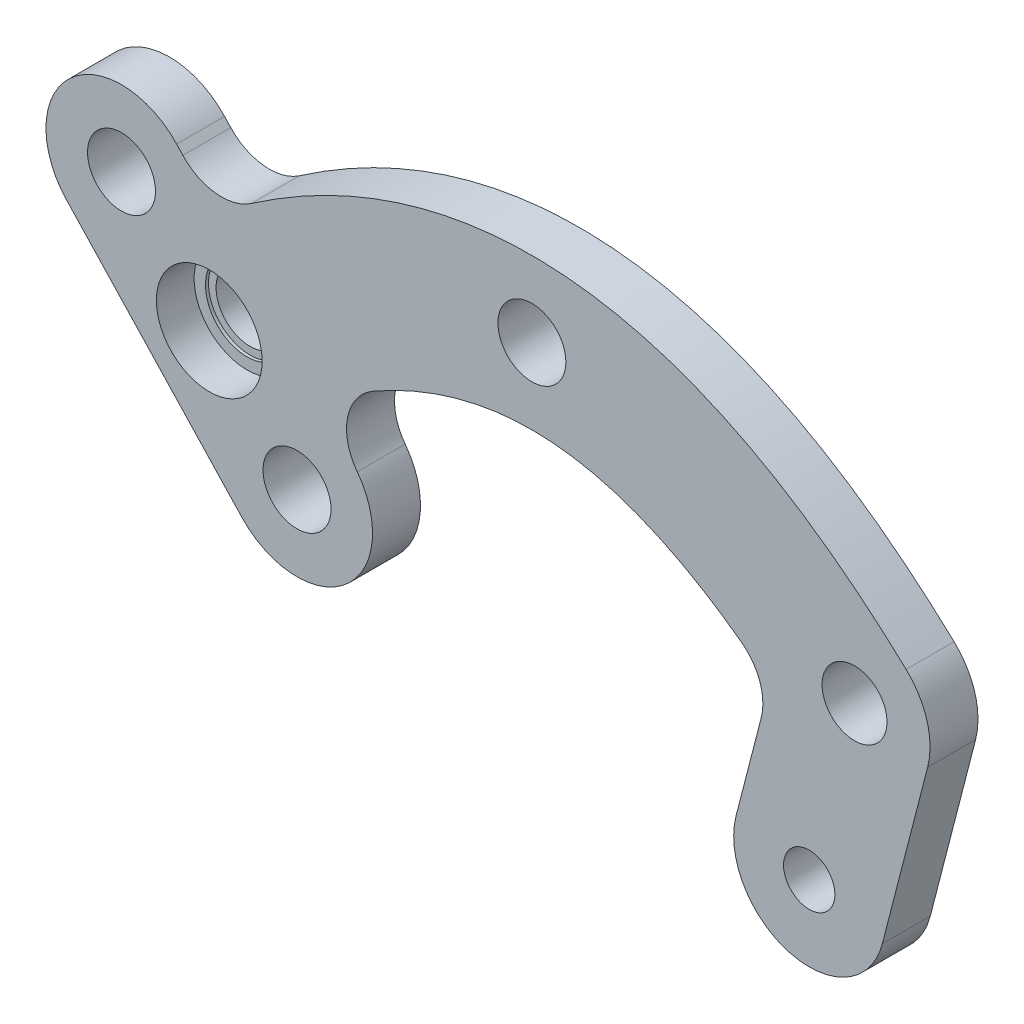
from build123d import *

# Parameters (mm, degrees)
BOSS_EXTRUDE1_DEPTH  = 1.5875
M4_CLEARANCE_HOLE1_D = 4.5
BOSS_EXTRUDE2_DEPTH  = 3.175
M3_CLEARANCE_HOLE1_D = 3.4
FILLET1_R            = 3.5
SKETCH8_R            = 2.15
CUT_EXTRUDE1_DEPTH   = 4.1750001
SKETCH9_R            = 2.75
SKETCH9_R_2          = 2.15
BOSS_EXTRUDE3_DEPTH  = 0.75
SKETCH11_R           = 3.5
CUT_EXTRUDE2_DEPTH   = 2.5
SKETCH12_R           = 2.75
CUT_EXTRUDE3_DEPTH   = 0.2
SKETCH13_R           = 3
SKETCH13_R_2         = 2.25
BOSS_EXTRUDE5_DEPTH  = 1.5


with BuildPart() as part:
    # Sketch2 → Boss-Extrude1 (new body, symmetric)
    with BuildSketch(Plane.XY):
        with BuildLine():
            add(Edge.make_bspline(
                [(-24.777431429, -6.350183234), (-24.299810251, -5.902972393), (-23.32289496, -5.01651393), (-22.058866471, -3.944003435), (-21.276036232, -3.316259916), (-20.98344634, -3.086723573)],
                knots=[0, 0, 0, 0, 0.03125, 0.0625, 0.081068463, 0.081068463, 0.081068463, 0.081068463], degree=3))
            Line((-24.777431429, -6.350183234), (-21.36, -10))
            add(Edge.make_bspline(
                [(-21.36, -10), (-20.09052587, -8.81135381), (-18.821051739, -7.728673603), (-17.551577609, -6.751959378)],
                knots=[0, 0, 0, 0, 0.089148464, 0.089148464, 0.089148464, 0.089148464], degree=3))
            Line((-17.551577609, -6.751959378), (-20.98344634, -3.086723573))
        make_face()
        with BuildLine():
            Line((-21.36, -10), (-24.777431429, -6.350183234))
            ThreePointArc((-24.777431429, -6.350183234), (-26.357299125, -9.8356788), (-25.009816701, -13.417431499))
            ThreePointArc((-25.009816701, -13.417431499), (-21.5243212, -14.997299125), (-17.942568571, -13.649816766))
            Line((-17.942568571, -13.649816766), (-21.36, -10))
        make_face()
        with BuildLine():
            ThreePointArc((-25.009816701, -13.417431499), (-26.357299125, -9.8356788), (-24.777431429, -6.350183234))
            add(Edge.make_bspline(
                [(-24.777431429, -6.350183234), (-24.299810251, -5.902972393), (-23.32289496, -5.01651393), (-22.058866471, -3.944003435), (-21.276036232, -3.316259916), (-20.98344634, -3.086723573)],
                knots=[0, 0, 0, 0, 0.03125, 0.0625, 0.081068463, 0.081068463, 0.081068463, 0.081068463], degree=3))
            Line((-20.98344634, -3.086723573), (-21.127614663, -2.932751805))
            Line((-21.127614663, -2.932751805), (-23.519816663, -0.377880068))
            ThreePointArc((-23.519816663, -0.377880068), (-30.587064859, -0.145494731), (-30.819450196, -7.212742926))
            Line((-30.819450196, -7.212742926), (-28.427248195, -9.767614663))
            Line((-28.427248195, -9.767614663), (-25.009816701, -13.417431499))
        make_face()
        with BuildLine():
            add(Edge.make_bspline(
                [(-21.36, -10), (-20.09052587, -8.81135381), (-18.821051739, -7.728673603), (-17.551577609, -6.751959378)],
                knots=[0, 0, 0, 0, 0.089148464, 0.089148464, 0.089148464, 0.089148464], degree=3))
            Line((-21.36, -10), (-17.942568571, -13.649816766))
            add(Edge.make_bspline(
                [(-17.942568571, -13.649816766), (-17.543072686, -13.275756949), (-16.7212792, -12.530114496), (-15.44829951, -11.450473224), (-14.582019434, -10.770813046), (-14.116024052, -10.421130577)],
                knots=[0, 0, 0, 0, 0.03125, 0.0625, 0.099339971, 0.099339971, 0.099339971, 0.099339971], degree=3))
            Line((-14.116024052, -10.421130577), (-14.292751805, -10.232385337))
            Line((-14.292751805, -10.232385337), (-17.551577609, -6.751959378))
        make_face()
        with BuildLine():
            ThreePointArc((-17.942568571, -13.649816766), (-21.5243212, -14.997299125), (-25.009816701, -13.417431499))
            Line((-25.009816701, -13.417431499), (-21.592385337, -17.067248195))
            Line((-21.592385337, -17.067248195), (-19.200183337, -19.622119932))
            ThreePointArc((-19.200183337, -19.622119932), (-12.132935141, -19.854505269), (-11.900549804, -12.787257074))
            Line((-11.900549804, -12.787257074), (-14.116024052, -10.421130577))
            add(Edge.make_bspline(
                [(-17.942568571, -13.649816766), (-17.543072686, -13.275756949), (-16.7212792, -12.530114496), (-15.44829951, -11.450473224), (-14.582019434, -10.770813046), (-14.116024052, -10.421130577)],
                knots=[0, 0, 0, 0, 0.03125, 0.0625, 0.099339971, 0.099339971, 0.099339971, 0.099339971], degree=3))
        make_face()
        with BuildLine():
            add(Edge.make_bspline(
                [(-20.98344634, -3.086723573), (-20.291201445, -2.543658465), (-18.603117827, -1.28817338), (-15.885096675, 0.462779531), (-11.785009924, 2.624744664), (-6.509375137, 4.48808894), (0, 5.25595553), (6.509375137, 4.48808894), (11.785009924, 2.624744664), (15.885096675, 0.462779531), (18.901874802, -1.480633029), (21.37388106, -3.362802893), (23.32289496, -5.01651393), (24.299810251, -5.902972393), (24.777431429, -6.350183234)],
                knots=[0.081068463, 0.081068463, 0.081068463, 0.081068463, 0.125, 0.1875, 0.25, 0.375, 0.5, 0.625, 0.75, 0.8125, 0.875, 0.9375, 0.96875, 1, 1, 1, 1], degree=3))
            Line((-20.98344634, -3.086723573), (-17.551577609, -6.751959378))
            Line((-17.551577609, -6.751959378), (-14.292751805, -10.232385337))
            Line((-14.292751805, -10.232385337), (-14.116024052, -10.421130577))
            add(Edge.make_bspline(
                [(-14.116024052, -10.421130577), (-13.791445759, -10.177567349), (-12.680801028, -9.370838959), (-10.815202086, -8.171392792), (-7.794818062, -6.582915934), (-4.170679183, -5.321481205), (0, -4.839259398), (4.170679183, -5.321481205), (7.794818062, -6.582915934), (10.815202086, -8.171392792), (13.136984474, -9.664132159), (15.119482265, -11.171596294), (16.7212792, -12.530114496), (17.543072686, -13.275756949), (17.942568571, -13.649816766)],
                knots=[0.099339971, 0.099339971, 0.099339971, 0.099339971, 0.125, 0.1875, 0.25, 0.375, 0.5, 0.625, 0.75, 0.8125, 0.875, 0.9375, 0.96875, 1, 1, 1, 1], degree=3))
            ThreePointArc((17.942568571, -13.649816766), (25.009816766, -13.417431429), (24.777431429, -6.350183234))
        make_face()
    extrude(amount=BOSS_EXTRUDE1_DEPTH, both=True)

    # M4 Clearance Hole1 (through all)
    with Locations(Plane.XY.offset(1.5875)):
        with Locations((-21.359999999, -9.999999999), (0, 0), (-15.550366571, -16.204688503), (-27.169633429, -3.795311497)):
            Hole(M4_CLEARANCE_HOLE1_D / 2)

    # Sketch5 → Boss-Extrude2 (add)
    with BuildSketch(Plane(origin=(0, 0, -1.5875), x_dir=(-1, 0, 0), z_dir=(0, 0, -1))):
        with BuildLine():
            ThreePointArc((-23.201229183, -22.868950039), (-17.11, -26.460179221), (-13.518770817, -20.368950039))
            Line((-13.518770817, -20.368950039), (-16.518770817, -8.75))
            ThreePointArc((-16.518770817, -8.75), (-22.61, -5.158770817), (-26.201229183, -11.25))
            Line((-26.201229183, -11.25), (-23.201229183, -22.868950039))
        make_face()
    extrude(amount=-BOSS_EXTRUDE2_DEPTH)

    # M3 Clearance Hole1 (through all)
    with Locations(Plane(origin=(0, 0, -1.5875), x_dir=(-1, 0, 0), z_dir=(0, 0, -1))):
        with Locations((-18.36, -21.618950039)):
            Hole(M3_CLEARANCE_HOLE1_D / 2)

    # Fillet1
    fillet1_edges = [part.edges().sort_by_distance(p)[0] for p in [
        (15.75315909, -11.715201468, -0.79375),
        (-20.98344634, -3.086723573, -0.79375),
        (-14.116024052, -10.421130577, 0.79375),
    ]]
    fillet(fillet1_edges, radius=FILLET1_R)

    # Sketch8 → Cut-Extrude1 (cut, through all)
    with BuildSketch(Plane(origin=(0, 0, -1.5875), x_dir=(-1, 0, 0), z_dir=(0, 0, -1))):
        with Locations((-21.36, -10)):
            Circle(SKETCH8_R)
    extrude(amount=-CUT_EXTRUDE1_DEPTH, mode=Mode.SUBTRACT)

    # Sketch9 → Boss-Extrude3 (add)
    with BuildSketch(Plane(origin=(0, 0, -1.5875), x_dir=(-1, 0, 0), z_dir=(0, 0, -1))):
        with Locations((-21.36, -10)):
            Circle(SKETCH9_R)
        with Locations((-21.36, -10)):
            Circle(SKETCH9_R_2, mode=Mode.SUBTRACT)
    extrude(amount=BOSS_EXTRUDE3_DEPTH)

    # Sketch11 → Cut-Extrude2 (cut)
    with BuildSketch(Plane.XY.offset(1.5875)):
        with Locations((-21.359999999, -9.999999999)):
            Circle(SKETCH11_R)
    extrude(amount=-CUT_EXTRUDE2_DEPTH, mode=Mode.SUBTRACT)

    # Sketch12 → Cut-Extrude3 (cut)
    with BuildSketch(Plane.XY.offset(-0.9125)):
        with Locations((-21.359999999, -9.999999999)):
            Circle(SKETCH12_R)
    extrude(amount=-CUT_EXTRUDE3_DEPTH, mode=Mode.SUBTRACT)

    # Sketch13 → Boss-Extrude5 (add)
    with BuildSketch(Plane(origin=(0, 0, -1.5875), x_dir=(-1, 0, 0), z_dir=(0, 0, -1))):
        with Locations((21.359999999, -9.999999999)):
            Circle(SKETCH13_R)
        with Locations((21.359999999, -9.999999999)):
            Circle(SKETCH13_R_2, mode=Mode.SUBTRACT)
    extrude(amount=BOSS_EXTRUDE5_DEPTH)


solid = part.part
